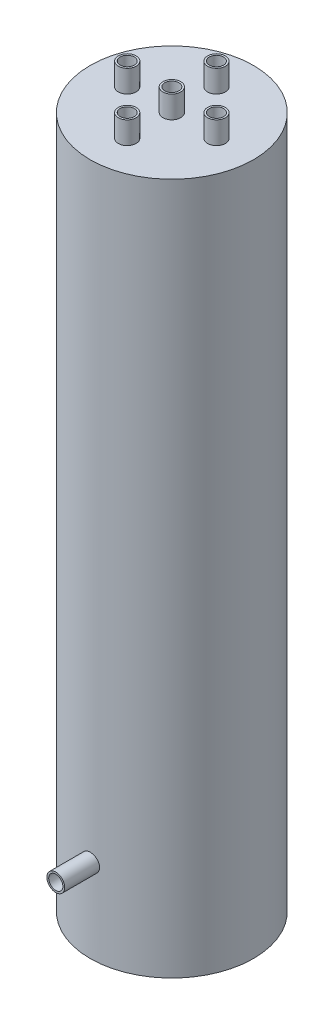
from build123d import *

# Parameters (mm, degrees)
SKETCH2_R           = 36.6
SKETCH2_R_2         = 29.45
BOSS_EXTRUDE1_DEPTH = 140
SKETCH3_R           = 36.6
BOSS_EXTRUDE2_DEPTH = 15
SKETCH5_R           = 3.175
CUT_EXTRUDE1_DEPTH  = 52
SKETCH6_R           = 4
SKETCH6_R_2         = 3.175
BOSS_EXTRUDE4_DEPTH = 52
SKETCH7_R           = 3.175
CUT_EXTRUDE2_DEPTH  = 52
SKETCH8_R           = 4
SKETCH8_R_2         = 3.175
BOSS_EXTRUDE5_DEPTH = 10
SKETCH4_R           = 36.6
BOSS_EXTRUDE3_DEPTH = 15


with BuildPart() as part:
    # Sketch2 → Boss-Extrude1 (new body, symmetric)
    with BuildSketch(Plane(origin=(0, 0, 0), x_dir=(1, 0, 0), z_dir=(0, 1, 0))):
        Circle(SKETCH2_R)
        Circle(SKETCH2_R_2, mode=Mode.SUBTRACT)
    extrude(amount=BOSS_EXTRUDE1_DEPTH, both=True)

    # Sketch3 → Boss-Extrude2 (add)
    with BuildSketch(Plane(origin=(0, 140, 0), x_dir=(1, 0, 0), z_dir=(0, 1, 0))):
        Circle(SKETCH3_R)
    extrude(amount=BOSS_EXTRUDE2_DEPTH)

    # Sketch5 → Cut-Extrude1 (cut)
    with BuildSketch(Plane.XY):
        with Locations((0, -117.704465643)):
            Circle(SKETCH5_R)
    extrude(amount=CUT_EXTRUDE1_DEPTH, mode=Mode.SUBTRACT)

    # Sketch6 → Boss-Extrude4 (add)
    with BuildSketch(Plane.XY):
        with Locations((0, -117.704465643)):
            Circle(SKETCH6_R)
        with Locations((0, -117.704465643)):
            Circle(SKETCH6_R_2, mode=Mode.SUBTRACT)
    extrude(amount=BOSS_EXTRUDE4_DEPTH)

    # Sketch7 → Cut-Extrude2 (cut)
    with BuildSketch(Plane(origin=(0, 155, 0), x_dir=(1, 0, 0), z_dir=(0, 1, 0))):
        with Locations((0, 20)):
            Circle(SKETCH7_R)
        Circle(SKETCH7_R)
        with Locations((-20, 0)):
            Circle(SKETCH7_R)
        with Locations((20, 0)):
            Circle(SKETCH7_R)
        with Locations((0, -20)):
            Circle(SKETCH7_R)
    extrude(amount=-CUT_EXTRUDE2_DEPTH, mode=Mode.SUBTRACT)

    # Sketch8 → Boss-Extrude5 (add)
    with BuildSketch(Plane(origin=(0, 155, 0), x_dir=(1, 0, 0), z_dir=(0, 1, 0))):
        Circle(SKETCH8_R)
        Circle(SKETCH8_R_2, mode=Mode.SUBTRACT)
        with Locations((0, 20)):
            Circle(SKETCH8_R)
        with Locations((0, 20)):
            Circle(SKETCH8_R_2, mode=Mode.SUBTRACT)
        with Locations((20, 0)):
            Circle(SKETCH8_R)
        with Locations((20, 0)):
            Circle(SKETCH8_R_2, mode=Mode.SUBTRACT)
        with Locations((-20, 0)):
            Circle(SKETCH8_R)
        with Locations((-20, 0)):
            Circle(SKETCH8_R_2, mode=Mode.SUBTRACT)
        with Locations((0, -20)):
            Circle(SKETCH8_R)
        with Locations((0, -20)):
            Circle(SKETCH8_R_2, mode=Mode.SUBTRACT)
    extrude(amount=BOSS_EXTRUDE5_DEPTH)

    # Sketch4 → Boss-Extrude3 (add)
    with BuildSketch(Plane.XZ.offset(140)):
        Circle(SKETCH4_R)
    extrude(amount=BOSS_EXTRUDE3_DEPTH)


solid = part.part
